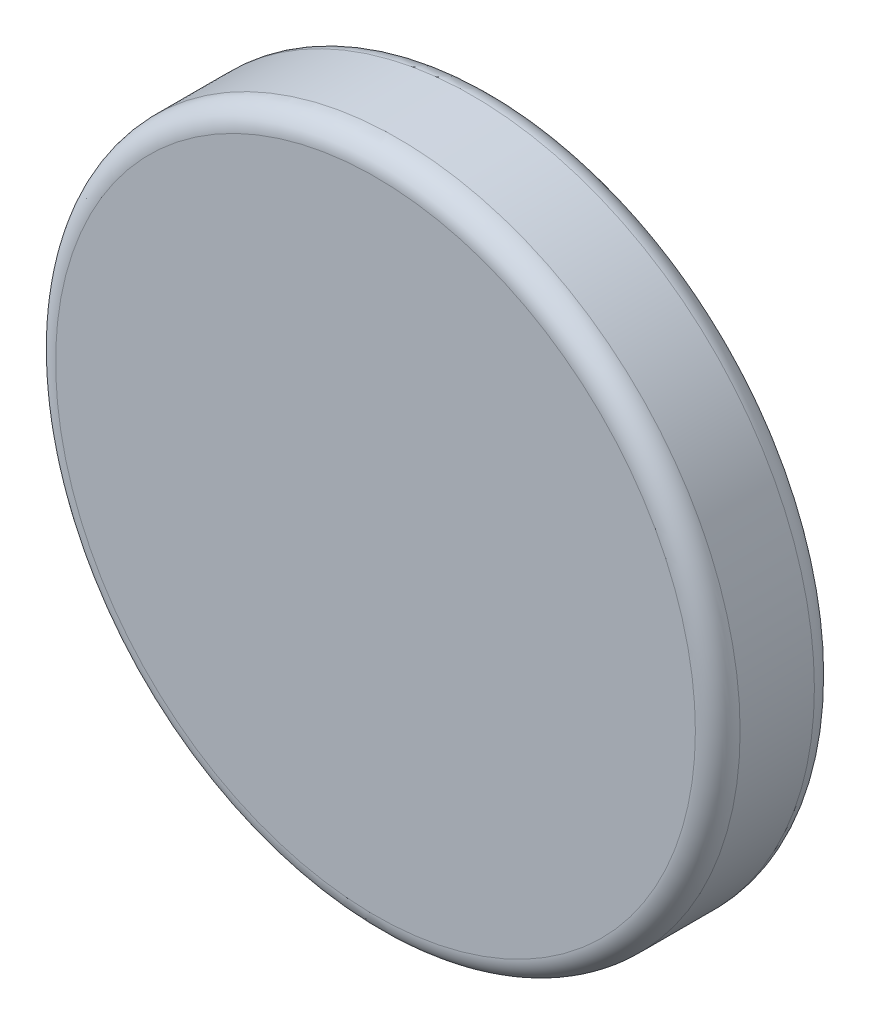
from build123d import *

# Parameters (mm, degrees)
SKICA1_R                     = 76.5
P_IDAT_VYSUNUT_M1_DEPTH      = 20
P_IDAT_VYSUNUT_M1_DEPTH_BACK = 6.6
ODEBRAT_VYSUNUT_M1_DEPTH     = 5
ZAOBLIT1_R                   = 2
ZAOBLIT2_R                   = 5


with BuildPart() as part:
    # Skica1 → Přidat vysunutím1 (new body, two sides)
    with BuildSketch(Plane.XY) as p_idat_vysunut_m1_sk:
        Circle(SKICA1_R)
    extrude(amount=P_IDAT_VYSUNUT_M1_DEPTH)
    extrude(p_idat_vysunut_m1_sk.sketch, amount=-P_IDAT_VYSUNUT_M1_DEPTH_BACK)

    # Skica2 → Odebrat vysunutím1 (cut)
    with BuildSketch(Plane(origin=(0, 0, -6.6), x_dir=(-1, 0, 0), z_dir=(0, 0, -1))):
        Polygon((25, -10), (48.8, -10), (48.8, 10), (25, 10), (25, 25), (10, 25), (10, 48.8), (-10, 48.8), (-10, 25), (-25, 25), (-25, 10), (-48.8, 10), (-48.8, -10), (-25, -10), (-25, -25), (-10, -25), (-10, -48.8), (10, -48.8), (10, -25), (25, -25), align=None)
    extrude(amount=-ODEBRAT_VYSUNUT_M1_DEPTH, mode=Mode.SUBTRACT)

    # Zaoblit1
    zaoblit1_edges = [part.edges().sort_by_distance(p)[0] for p in [
        (-25, -17.5, -6.6),
        (-36.9, -10, -6.6),
        (-48.8, 0, -6.6),
        (-36.9, 10, -6.6),
        (-25, 17.5, -6.6),
        (-17.5, 25, -6.6),
        (-10, 36.9, -6.6),
        (0, 48.8, -6.6),
        (10, 36.9, -6.6),
        (17.5, 25, -6.6),
        (25, 17.5, -6.6),
        (36.9, 10, -6.6),
        (48.8, 0, -6.6),
        (36.9, -10, -6.6),
        (25, -17.5, -6.6),
        (17.5, -25, -6.6),
        (10, -36.9, -6.6),
        (0, -48.8, -6.6),
        (-10, -36.9, -6.6),
        (-17.5, -25, -6.6),
    ]]
    fillet(zaoblit1_edges, radius=ZAOBLIT1_R)

    # Zaoblit2
    zaoblit2_edges = [part.edges().sort_by_distance(p)[0] for p in [
        (-76.5, 0, 20),
        (-76.5, 0, -6.6),
    ]]
    fillet(zaoblit2_edges, radius=ZAOBLIT2_R)


solid = part.part
